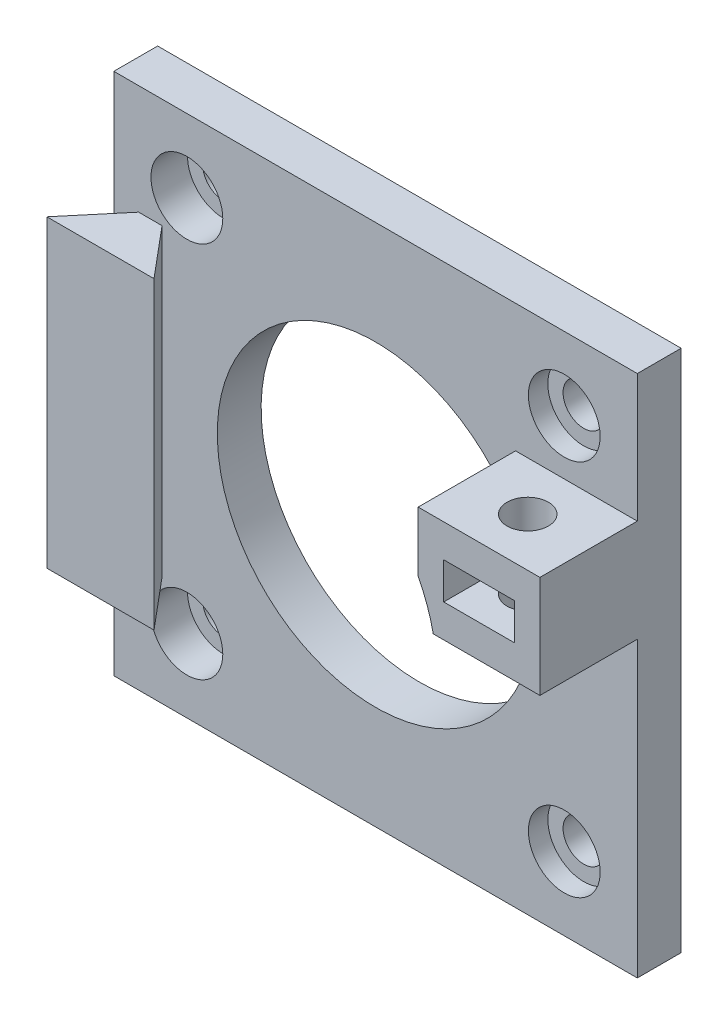
from build123d import *

# Parameters (mm, degrees)
CROQUIS1_W                   = 43
CROQUIS1_H                   = 43
CROQUIS1_R                   = 13
CROQUIS1_R_2                 = 1.7
SALIENTE_EXTRUIR1_DEPTH      = 3.6
CROQUIS2_R                   = 2.95
CORTAR_EXTRUIR1_DEPTH        = 1.6
SALIENTE_EXTRUIR2_DEPTH      = 8
CROQUIS4_R                   = 1.7
CORTAR_EXTRUIR2_DEPTH        = 10
CORTAR_EXTRUIR3_DEPTH        = 1.5
CORTAR_EXTRUIR3_DEPTH_BACK   = 1.5
SALIENTE_EXTRUIR3_DEPTH      = 12.5
SALIENTE_EXTRUIR3_DEPTH_BACK = 12.5
CROQUIS8_R                   = 2.95
CORTAR_EXTRUIR4_DEPTH        = 3


with BuildPart() as part:
    # Croquis1 → Saliente-Extruir1 (new body)
    with BuildSketch(Plane.XY):
        Rectangle(CROQUIS1_W, CROQUIS1_H)
        Circle(CROQUIS1_R, mode=Mode.SUBTRACT)
        with Locations((-15.5, 15.5)):
            Circle(CROQUIS1_R_2, mode=Mode.SUBTRACT)
        with Locations((-15.5, -15.5)):
            Circle(CROQUIS1_R_2, mode=Mode.SUBTRACT)
        with Locations((15.5, -15.5)):
            Circle(CROQUIS1_R_2, mode=Mode.SUBTRACT)
        with Locations((15.5, 15.5)):
            Circle(CROQUIS1_R_2, mode=Mode.SUBTRACT)
    extrude(amount=SALIENTE_EXTRUIR1_DEPTH)

    # Croquis2 → Cortar-Extruir1 (cut)
    with BuildSketch(Plane.XY.offset(3.6)):
        with Locations((-15.5, 15.5)):
            Circle(CROQUIS2_R)
        with Locations((15.5, 15.5)):
            Circle(CROQUIS2_R)
        with Locations((-15.5, -15.5)):
            Circle(CROQUIS2_R)
        with Locations((15.5, -15.5)):
            Circle(CROQUIS2_R)
    extrude(amount=-CORTAR_EXTRUIR1_DEPTH, mode=Mode.SUBTRACT)

    # Croquis3 → Saliente-Extruir2 (add)
    with BuildSketch(Plane.XY.offset(3.6)):
        with BuildLine():
            Line((21.5, 2.6), (12.737346662, 2.6))
            ThreePointArc((12.737346662, 2.6), (12.241687471, 4.375052899), (11.5, 6.062177826))
            Line((11.5, 6.062177826), (11.5, 11))
            Line((11.5, 11), (21.5, 11))
            Line((21.5, 11), (21.5, 2.6))
        make_face()
    extrude(amount=SALIENTE_EXTRUIR2_DEPTH)

    # Croquis4 → Cortar-Extruir2 (cut)
    with BuildSketch(Plane.XZ.offset(-2.6)):
        with Locations((16.5, 7.6)):
            Circle(CROQUIS4_R)
    extrude(amount=-CORTAR_EXTRUIR2_DEPTH, mode=Mode.SUBTRACT)

    # Croquis6 → Cortar-Extruir3 (cut, two sides)
    with BuildSketch(Plane(origin=(0, 6.8, 0), x_dir=(-1, 0, 0), z_dir=(0, -1, 0))) as cortar_extruir3_sk:
        Polygon((-13.598814897, -9.275), (-13.598814897, -15.925), (-19.401185103, -15.925), (-19.401185103, -9.275), (-19.401185103, -5.925), (-16.5, -4.25), (-13.598814897, -5.925), align=None)
    extrude(amount=CORTAR_EXTRUIR3_DEPTH, mode=Mode.SUBTRACT)
    extrude(cortar_extruir3_sk.sketch, amount=-CORTAR_EXTRUIR3_DEPTH_BACK, mode=Mode.SUBTRACT)

    # Croquis7 → Saliente-Extruir3 (add, two sides)
    with BuildSketch(Plane(origin=(0, 0, 0), x_dir=(1, 0, 0), z_dir=(0, 1, 0))) as saliente_extruir3_sk:
        Polygon((-22.9, -7.7), (-18.5, -2.456284193), (-14.1, -7.7), align=None)
    extrude(amount=SALIENTE_EXTRUIR3_DEPTH)
    extrude(saliente_extruir3_sk.sketch, amount=-SALIENTE_EXTRUIR3_DEPTH_BACK)

    # Croquis8 → Cortar-Extruir4 (cut)
    with BuildSketch(Plane.XY.offset(3.6)):
        with Locations((-15.5, -15.5)):
            Circle(CROQUIS8_R)
        with Locations((-15.5, 15.5)):
            Circle(CROQUIS8_R)
    extrude(amount=-CORTAR_EXTRUIR4_DEPTH, mode=Mode.SUBTRACT)


solid = part.part
